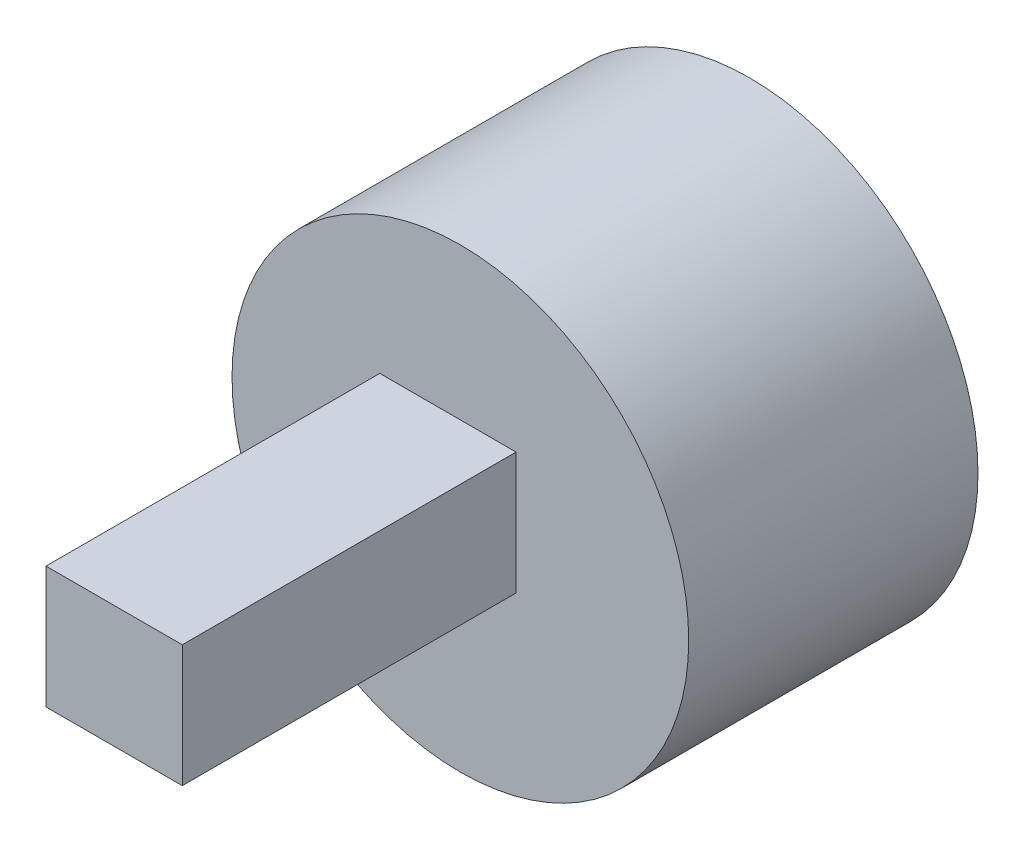
from build123d import *

# Parameters (mm, degrees)
SKETCH1_R           = 20.522720043
BOSS_EXTRUDE1_DEPTH = 26
SKETCH2_W           = 12.248280036
SKETCH2_H           = 10.968646874
BOSS_EXTRUDE2_DEPTH = 30


with BuildPart() as part:
    # Sketch1 → Boss-Extrude1 (new body)
    with BuildSketch(Plane.XY):
        Circle(SKETCH1_R)
    extrude(amount=BOSS_EXTRUDE1_DEPTH)

    # Sketch2 → Boss-Extrude2 (add)
    with BuildSketch(Plane.XY.offset(26)):
        with Locations((-1.119626677, 1.411896592)):
            Rectangle(SKETCH2_W, SKETCH2_H)
    extrude(amount=BOSS_EXTRUDE2_DEPTH)


solid = part.part
